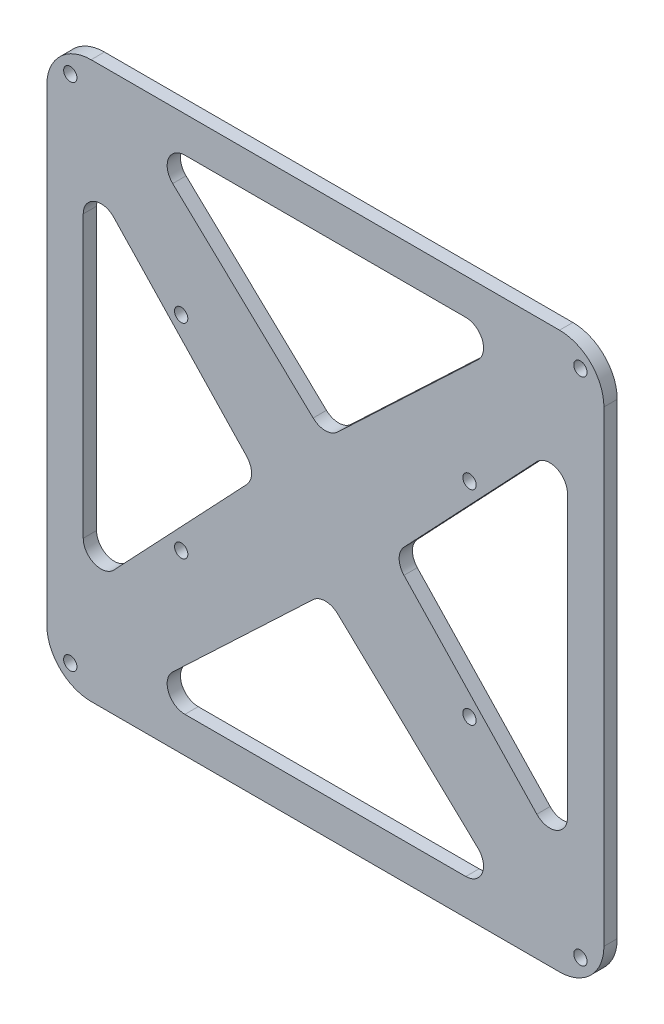
from build123d import *

# Parameters (mm, degrees)
SKETCH_1_W      = 125.6
SKETCH_1_H      = 125.3
SKETCH_1_R      = 1.5
EXTRUDE_1_DEPTH = 3
FILLET_1_R      = 10
FILLET_2_R      = 4


with BuildPart() as part:
    # 草图1 → 凸台-拉伸1 (new body)
    with BuildSketch(Plane.XY):
        with Locations((62.8, -62.65)):
            Rectangle(SKETCH_1_W, SKETCH_1_H)
        with Locations((30.3, -39.65)):
            Circle(SKETCH_1_R, mode=Mode.SUBTRACT)
        with Locations((95.3, -39.65)):
            Circle(SKETCH_1_R, mode=Mode.SUBTRACT)
        with Locations((95.3, -85.65)):
            Circle(SKETCH_1_R, mode=Mode.SUBTRACT)
        with Locations((30.3, -85.65)):
            Circle(SKETCH_1_R, mode=Mode.SUBTRACT)
        with Locations((120.3, -120.15)):
            Circle(SKETCH_1_R, mode=Mode.SUBTRACT)
        with Locations((5.3, -120.15)):
            Circle(SKETCH_1_R, mode=Mode.SUBTRACT)
        with Locations((5.3, -5.15)):
            Circle(SKETCH_1_R, mode=Mode.SUBTRACT)
        with Locations((120.3, -5.15)):
            Circle(SKETCH_1_R, mode=Mode.SUBTRACT)
        Polygon((21.089760081, -117.229442096), (104.510239919, -117.229442096), (62.8, -77.778125501), align=None, mode=Mode.SUBTRACT)
        Polygon((8.220557904, -104.360239919), (47.671874499, -62.65), (8.220557904, -20.939760081), align=None, mode=Mode.SUBTRACT)
        Polygon((21.089760081, -8.070557904), (62.8, -47.521874499), (104.510239919, -8.070557904), align=None, mode=Mode.SUBTRACT)
        Polygon((117.379442096, -20.939760081), (77.928125501, -62.65), (117.379442096, -104.360239919), align=None, mode=Mode.SUBTRACT)
    extrude(amount=EXTRUDE_1_DEPTH)

    # 圆角1
    fillet_1_edges = [part.edges().sort_by_distance(p)[0] for p in [
        (0, 0, 1.5),
        (125.6, 0, 1.5),
        (125.6, -125.3, 1.5),
        (0, -125.3, 1.5),
    ]]
    fillet(fillet_1_edges, radius=FILLET_1_R)

    # 圆角2
    fillet_2_edges = [part.edges().sort_by_distance(p)[0] for p in [
        (62.8, -77.778125501, 1.5),
        (21.089760081, -117.229442096, 1.5),
        (104.510239919, -117.229442096, 1.5),
        (47.671874499, -62.65, 1.5),
        (8.220557904, -20.939760081, 1.5),
        (8.220557904, -104.360239919, 1.5),
        (62.8, -47.521874499, 1.5),
        (104.510239919, -8.070557904, 1.5),
        (21.089760081, -8.070557904, 1.5),
        (77.928125501, -62.65, 1.5),
        (117.379442096, -104.360239919, 1.5),
        (117.379442096, -20.939760081, 1.5),
    ]]
    fillet(fillet_2_edges, radius=FILLET_2_R)


solid = part.part
